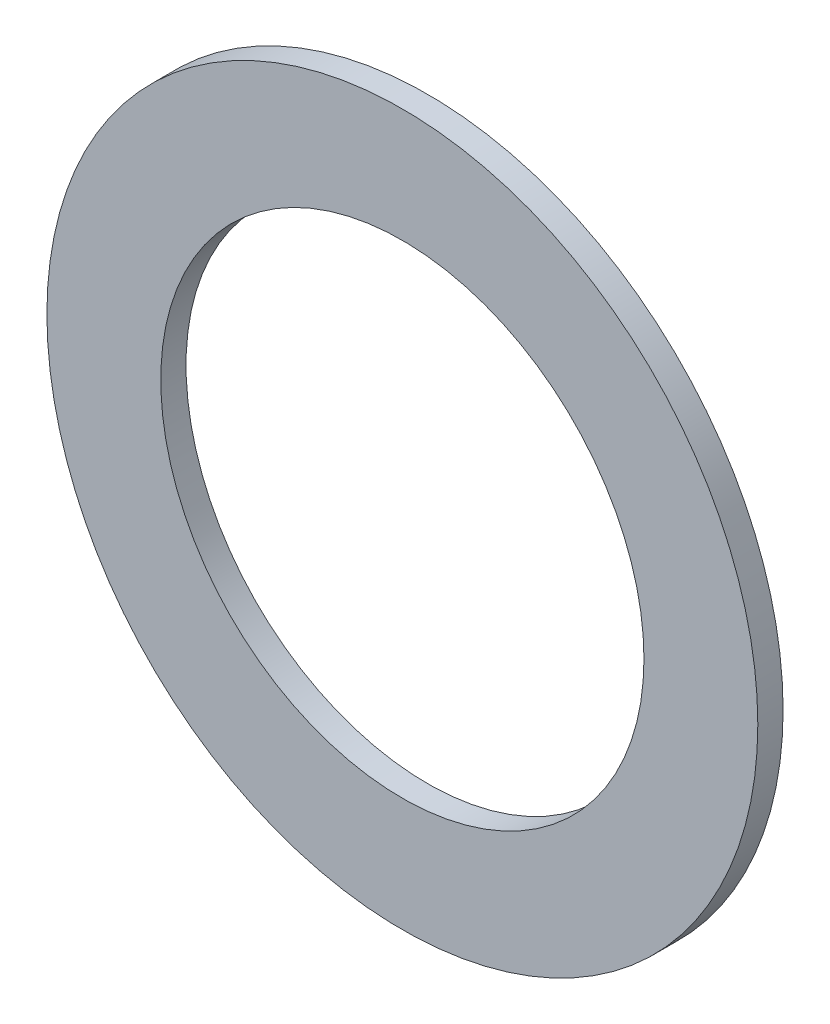
from build123d import *

# Parameters (mm, degrees)
SKETCH1_R           = 128
SKETCH1_R_2         = 87
BOSS_EXTRUDE2_DEPTH = 9.1


with BuildPart() as part:
    # Sketch1 → Boss-Extrude2 (new body)
    with BuildSketch(Plane.XY):
        Circle(SKETCH1_R)
        Circle(SKETCH1_R_2, mode=Mode.SUBTRACT)
    extrude(amount=BOSS_EXTRUDE2_DEPTH)


solid = part.part
